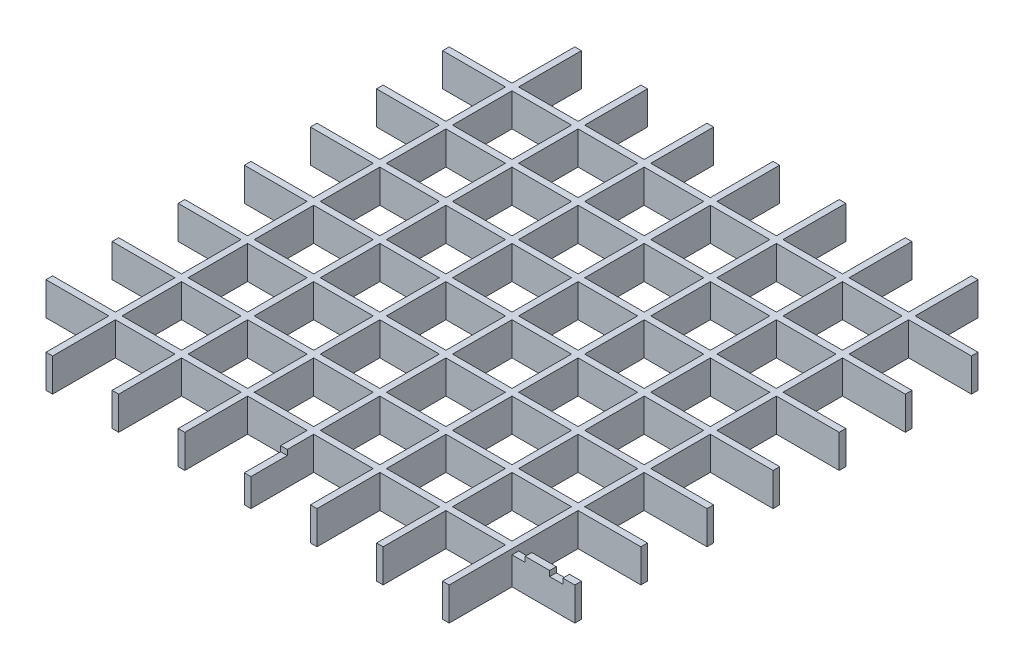
from build123d import *

# Parameters (mm, degrees)
SKETCH1_W           = 2.54
SKETCH1_H           = 203.2
BOSS_EXTRUDE1_DEPTH = 12.7
LPATTERN1_COUNT     = 7
LPATTERN1_PITCH     = 25.4
SKETCH2_W           = 203.2
SKETCH2_H           = 2.54
BOSS_EXTRUDE2_DEPTH = 12.7
LPATTERN2_COUNT     = 7
LPATTERN2_PITCH     = 25.4
SKETCH3_W           = 5.08
SKETCH3_H           = 2.54
SKETCH3_W_2         = 2.54
SKETCH3_H_2         = 13.97
CUT_EXTRUDE1_DEPTH  = 2.032


with BuildPart() as part:
    # Sketch1 → Boss-Extrude1 (new body)
    with BuildSketch(Plane(origin=(0, 0, 0), x_dir=(1, 0, 0), z_dir=(0, 1, 0))):
        Rectangle(SKETCH1_W, SKETCH1_H)
    extrude(amount=BOSS_EXTRUDE1_DEPTH)


with BuildPart() as lpattern1_1:
    # LPattern1: pattern copy
    add(part.part.moved(Location(Vector(1, 0, 0) * (1 * LPATTERN1_PITCH))))


with BuildPart() as lpattern1_2:
    # LPattern1: pattern copy
    add(part.part.moved(Location(Vector(1, 0, 0) * (2 * LPATTERN1_PITCH))))


with BuildPart() as lpattern1_3:
    # LPattern1: pattern copy
    add(part.part.moved(Location(Vector(1, 0, 0) * (3 * LPATTERN1_PITCH))))


with BuildPart() as lpattern1_4:
    # LPattern1: pattern copy
    add(part.part.moved(Location(Vector(1, 0, 0) * (4 * LPATTERN1_PITCH))))


with BuildPart() as lpattern1_5:
    # LPattern1: pattern copy
    add(part.part.moved(Location(Vector(1, 0, 0) * (5 * LPATTERN1_PITCH))))


with BuildPart() as lpattern1_6:
    # LPattern1: pattern copy
    add(part.part.moved(Location(Vector(1, 0, 0) * (6 * LPATTERN1_PITCH))))


with BuildPart() as part_1:
    add(part.part)

    add(lpattern1_1.part)  # Boss-Extrude2 merges LPattern1_1

    add(lpattern1_2.part)  # Boss-Extrude2 merges LPattern1_2

    add(lpattern1_3.part)  # Boss-Extrude2 merges LPattern1_3

    add(lpattern1_4.part)  # Boss-Extrude2 merges LPattern1_4

    add(lpattern1_5.part)  # Boss-Extrude2 merges LPattern1_5

    add(lpattern1_6.part)  # Boss-Extrude2 merges LPattern1_6
    # Sketch2 → Boss-Extrude2 (add)
    with BuildSketch(Plane(origin=(0, 0, 0), x_dir=(1, 0, 0), z_dir=(0, 1, 0))):
        with Locations((76.2, 76.2)):
            Rectangle(SKETCH2_W, SKETCH2_H)
    boss_extrude2 = extrude(amount=BOSS_EXTRUDE2_DEPTH)

    # LPattern2: Boss-Extrude2 ×7
    with Locations(*[(0, 0, i * LPATTERN2_PITCH) for i in range(1, LPATTERN2_COUNT)]):
        add(boss_extrude2)

    # Sketch3 → Cut-Extrude1 (cut)
    with BuildSketch(Plane(origin=(0, 12.7, 0), x_dir=(1, 0, 0), z_dir=(0, 1, 0))):
        with Locations((156.21, -76.2)):
            Rectangle(SKETCH3_W, SKETCH3_H)
        with Locations((170.688, -76.2)):
            Rectangle(SKETCH3_W, SKETCH3_H)
        with Locations((76.2, -94.615)):
            Rectangle(SKETCH3_W_2, SKETCH3_H_2)
    extrude(amount=-CUT_EXTRUDE1_DEPTH, mode=Mode.SUBTRACT)


solid = part_1.part
